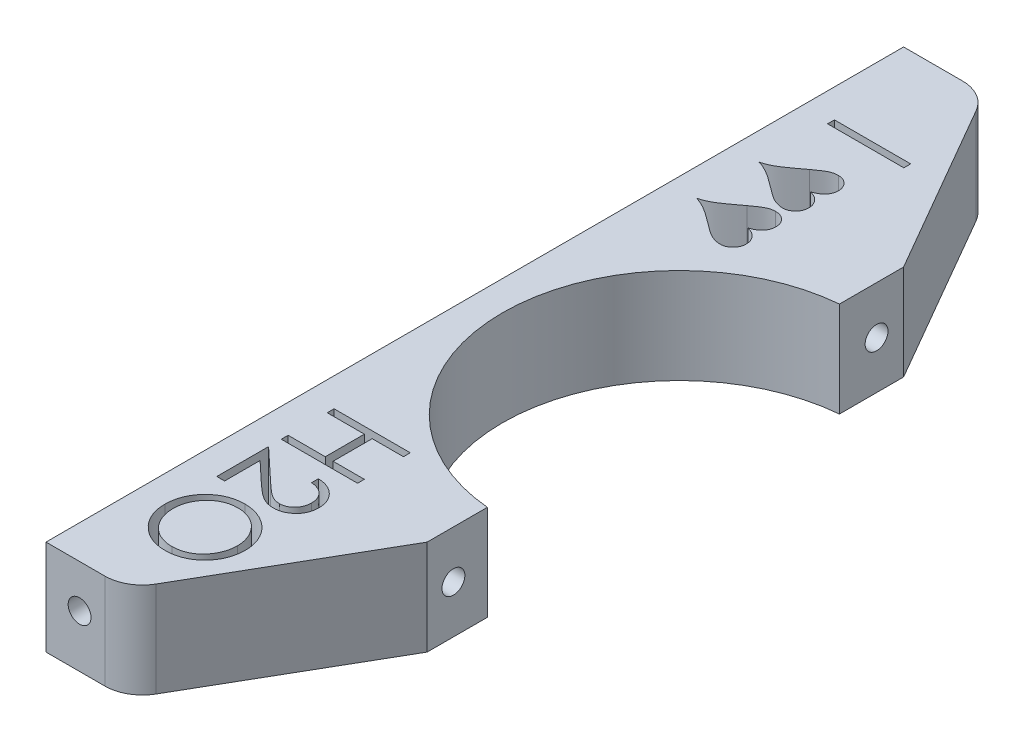
from build123d import *

# Parameters (mm, degrees)
SKETCH1_W               = 76.2
SKETCH1_H               = 25.4
BOSS_EXTRUDE1_DEPTH     = 228.6
CUT_EXTRUDE1_DEPTH      = 26.4
CUT_EXTRUDE2_DEPTH      = 1
CUT_EXTRUDE2_DEPTH_BACK = 26.4
FILLET1_R               = 10
SKETCH4_W               = 20.32
SKETCH4_H               = 1.823589744
CUT_EXTRUDE4_DEPTH      = 1
CUT_EXTRUDE4_DEPTH_BACK = 26.4
SKETCH5_R               = 3.048
CUT_EXTRUDE5_DEPTH      = 9.525
SKETCH6_R               = 3.048
CUT_EXTRUDE6_DEPTH      = 9.525
SKETCH7_R               = 3.048
CUT_EXTRUDE7_DEPTH      = 9.525


with BuildPart() as part:
    # Sketch1 → Boss-Extrude1 (new body)
    with BuildSketch(Plane.XY):
        with Locations((-76.99375, 46.83125)):
            Rectangle(SKETCH1_W, SKETCH1_H)
    extrude(amount=BOSS_EXTRUDE1_DEPTH)

    # Sketch2 → Cut-Extrude1 (cut, through all)
    with BuildSketch(Plane(origin=(0, 59.53125, 0), x_dir=(1, 0, 0), z_dir=(0, 1, 0))):
        with BuildLine():
            Line((-64.29375, -228.6), (-64.29375, -161.756428709))
            ThreePointArc((-64.29375, -161.756428709), (-107.195620062, -114.82835216), (-64.29375, -67.90027561))
            Line((-64.29375, -67.90027561), (-64.29375, 0))
            Line((-64.29375, 0), (-17.281394977, 0))
            Line((-17.281394977, 0), (-17.281394977, -228.6))
            Line((-17.281394977, -228.6), (-64.29375, -228.6))
        make_face()
    extrude(amount=-CUT_EXTRUDE1_DEPTH, mode=Mode.SUBTRACT)

    # Sketch3 → Cut-Extrude2 (cut, two sides)
    with BuildSketch(Plane(origin=(0, 59.53125, 0), x_dir=(1, 0, 0), z_dir=(0, 1, 0))) as cut_extrude2_sk:
        Polygon((-93.623143675, -228.6), (-64.29375, -177.8), (-64.29375, -228.6), align=None)
        Polygon((-64.29375, -50.8), (-64.29375, 0), (-93.623143675, 0), align=None)
    extrude(amount=CUT_EXTRUDE2_DEPTH, mode=Mode.SUBTRACT)
    extrude(cut_extrude2_sk.sketch, amount=-CUT_EXTRUDE2_DEPTH_BACK, mode=Mode.SUBTRACT)

    # Fillet1
    fillet1_edges = [part.edges().sort_by_distance(p)[0] for p in [
        (-93.623143675, 46.83125, 228.6),
        (-93.623143675, 46.83125, 0),
    ]]
    fillet(fillet1_edges, radius=FILLET1_R)

    # Sketch4 → Cut-Extrude4 (cut, two sides)
    with BuildSketch(Plane(origin=(0, 59.53125, 0), x_dir=(1, 0, 0), z_dir=(0, 1, 0))) as cut_extrude4_sk:
        with Locations((-97.31375, -26.963076923)):
            Rectangle(SKETCH4_W, SKETCH4_H)
        with BuildLine():
            add(Edge.make_bspline(
                [(-107.803461538, -45.854326923), (-107.526850389, -45.776645874), (-106.977385254, -45.622338906), (-106.178370987, -45.326274398), (-105.406394948, -44.9832244), (-104.770011222, -44.650701308), (-104.231404491, -44.329009584), (-103.753074851, -44.017533501), (-103.196094974, -43.643903935), (-102.565670745, -43.203380674), (-101.859529023, -42.696128207), (-101.076301016, -42.123935851), (-100.21751599, -41.484674215), (-99.622737732, -41.033947345), (-99.312371795, -40.79875)],
                knots=[0, 0, 0, 0, 0.000861652, 0.0017116, 0.002553488, 0.003394667, 0.003863783, 0.004435107, 0.00510684, 0.005875823, 0.00674223, 0.007715159, 0.008785712, 0.009953956, 0.009953956, 0.009953956, 0.009953956], degree=3))
            add(Edge.make_bspline(
                [(-99.312371795, -40.79875), (-99.165005098, -40.686776497), (-98.879106872, -40.46954271), (-98.455046356, -40.16561253), (-98.05592924, -39.885064707), (-97.683714936, -39.625677675), (-97.327760486, -39.403686206), (-96.998383735, -39.20360212), (-96.694197784, -39.027601265), (-96.320102113, -38.831590085), (-95.862629455, -38.632592026), (-95.302473383, -38.465056638), (-94.735792043, -38.358092228), (-94.353592554, -38.346123378), (-94.163173077, -38.340160256)],
                knots=[0, 0, 0, 0, 0.000555219, 0.00107715, 0.001565017, 0.002018893, 0.002437859, 0.002823206, 0.003175111, 0.003491906, 0.004089994, 0.004668194, 0.005243073, 0.005813875, 0.005813875, 0.005813875, 0.005813875], degree=3))
            add(Edge.make_bspline(
                [(-94.163173077, -38.340160256), (-94.039532597, -38.343169019), (-93.795337572, -38.349111449), (-93.438467093, -38.399565361), (-93.095126352, -38.477673481), (-92.765590485, -38.584457436), (-92.454695099, -38.735593374), (-92.157137289, -38.909977549), (-91.872167775, -39.114107608), (-91.612471479, -39.355142211), (-91.367949986, -39.611963694), (-91.155842297, -39.888618702), (-90.978381001, -40.182715606), (-90.832339204, -40.490884924), (-90.717760629, -40.81414718), (-90.635589469, -41.152234527), (-90.586236459, -41.505551865), (-90.580138886, -41.747022413), (-90.577051282, -41.869294872)],
                knots=[0, 0, 0, 0, 0.000370774, 0.000732295, 0.001078886, 0.001426433, 0.001768743, 0.00211361, 0.002460464, 0.002817789, 0.003174883, 0.003523334, 0.003861211, 0.004203521, 0.004544692, 0.004888259, 0.005245747, 0.005612454, 0.005612454, 0.005612454, 0.005612454], degree=3))
            add(Edge.make_bspline(
                [(-90.577051282, -41.869294872), (-90.579056913, -41.98473993), (-90.583010511, -42.212310801), (-90.624542712, -42.54759844), (-90.694929051, -42.869706417), (-90.786367328, -43.180276651), (-90.911204412, -43.474585155), (-91.057382126, -43.757737619), (-91.233564303, -44.027555167), (-91.438547428, -44.283193658), (-91.665878946, -44.529712244), (-91.925004608, -44.756344994), (-92.206906676, -44.973872335), (-92.517528017, -45.17728796), (-92.855603114, -45.367167084), (-93.218552431, -45.54793869), (-93.610998149, -45.710224252), (-93.884524314, -45.805482819), (-94.024775641, -45.854326923)],
                knots=[0, 0, 0, 0, 0.000346209, 0.000682464, 0.001011396, 0.001334611, 0.001652111, 0.001968905, 0.002289547, 0.002616939, 0.002951019, 0.003294127, 0.003648285, 0.00401859, 0.004406849, 0.00481098, 0.005234313, 0.005679806, 0.005679806, 0.005679806, 0.005679806], degree=3))
            add(Edge.make_bspline(
                [(-94.024775641, -45.854326923), (-93.881701598, -45.894489877), (-93.600961616, -45.973297652), (-93.200557373, -46.120656163), (-92.82539439, -46.28160126), (-92.484783147, -46.47115287), (-92.168531658, -46.672206164), (-91.886208473, -46.900131649), (-91.627672844, -47.141889845), (-91.335411327, -47.493773851), (-91.027166465, -47.952603298), (-90.758608176, -48.537588378), (-90.59050546, -49.146207833), (-90.570712948, -49.561512201), (-90.560769231, -49.770160256)],
                knots=[0, 0, 0, 0, 0.000445642, 0.000874439, 0.001279061, 0.001668897, 0.002042609, 0.002401784, 0.002755919, 0.00310251, 0.003771983, 0.004407674, 0.00502674, 0.005651772, 0.005651772, 0.005651772, 0.005651772], degree=3))
            add(Edge.make_bspline(
                [(-90.560769231, -49.770160256), (-90.563772929, -49.892440815), (-90.569671777, -50.132582901), (-90.61999156, -50.485774832), (-90.701901642, -50.823261745), (-90.811068738, -51.149328656), (-90.958610493, -51.458661419), (-91.13908087, -51.751983882), (-91.348500386, -52.032954331), (-91.590525137, -52.29279298), (-91.852510811, -52.530386842), (-92.126933023, -52.742027152), (-92.41605427, -52.916070217), (-92.716313319, -53.059234211), (-93.025679896, -53.176442916), (-93.349204083, -53.250143635), (-93.682474829, -53.303154795), (-93.909222366, -53.308687087), (-94.024775641, -53.31150641)],
                knots=[0, 0, 0, 0, 0.000366708, 0.000720163, 0.001067686, 0.001407519, 0.001749829, 0.0020933, 0.002439293, 0.002799367, 0.003156692, 0.003499438, 0.003837315, 0.004166851, 0.004496537, 0.004827277, 0.005160587, 0.005506964, 0.005506964, 0.005506964, 0.005506964], degree=3))
            add(Edge.make_bspline(
                [(-94.024775641, -53.31150641), (-94.220654224, -53.305714004), (-94.620620707, -53.293886431), (-95.227857333, -53.178005622), (-95.85477451, -53.008046529), (-96.391423166, -52.809179847), (-96.840036094, -52.598941793), (-97.216654097, -52.403726826), (-97.62024064, -52.161809139), (-98.059578877, -51.883565828), (-98.527688648, -51.562306126), (-99.029712667, -51.204350273), (-99.55962579, -50.802562277), (-99.921955972, -50.519599731), (-100.110192308, -50.372596154)],
                knots=[0, 0, 0, 0, 0.000587058, 0.001198719, 0.001848473, 0.002534991, 0.00291197, 0.003334363, 0.003806981, 0.004323038, 0.004894318, 0.005509935, 0.006172617, 0.006889131, 0.006889131, 0.006889131, 0.006889131], degree=3))
            add(Edge.make_bspline(
                [(-100.110192308, -50.372596154), (-100.313314069, -50.213328317), (-100.710768628, -49.901684071), (-101.302991426, -49.451440132), (-101.880381987, -49.03087008), (-102.436724331, -48.629388675), (-102.979241831, -48.261081202), (-103.500814577, -47.911617278), (-104.008880001, -47.592937543), (-104.496432979, -47.293108158), (-104.970081949, -47.025245762), (-105.423757012, -46.780312483), (-105.863265044, -46.563857205), (-106.282910465, -46.368602402), (-106.686881208, -46.199413555), (-107.07565551, -46.063235105), (-107.443195271, -45.941392767), (-107.686337002, -45.882632506), (-107.803461538, -45.854326923)],
                knots=[0, 0, 0, 0, 0.00077435, 0.001515195, 0.002231651, 0.0029173, 0.003573272, 0.004198715, 0.004800628, 0.005372372, 0.005915629, 0.006432825, 0.006918872, 0.007385119, 0.007821291, 0.00823201, 0.008620781, 0.008982118, 0.008982118, 0.008982118, 0.008982118], degree=3))
        make_face()
        with BuildLine():
            add(Edge.make_bspline(
                [(-107.803461538, -62.527147436), (-107.526850389, -62.449466387), (-106.977385254, -62.295159419), (-106.178370987, -61.999094911), (-105.406394948, -61.656044913), (-104.770011222, -61.32352182), (-104.231404491, -61.001830097), (-103.753074851, -60.690354014), (-103.196094974, -60.316724447), (-102.565670745, -59.876201187), (-101.859529023, -59.36894872), (-101.076301016, -58.796756364), (-100.21751599, -58.157494728), (-99.622737732, -57.706767858), (-99.312371795, -57.471570513)],
                knots=[0, 0, 0, 0, 0.000861652, 0.0017116, 0.002553488, 0.003394667, 0.003863783, 0.004435107, 0.00510684, 0.005875823, 0.00674223, 0.007715159, 0.008785712, 0.009953956, 0.009953956, 0.009953956, 0.009953956], degree=3))
            add(Edge.make_bspline(
                [(-99.312371795, -57.471570513), (-99.165005098, -57.35959701), (-98.879106872, -57.142363223), (-98.455046356, -56.838433043), (-98.05592924, -56.55788522), (-97.683714936, -56.298498188), (-97.327760486, -56.076506719), (-96.998383735, -55.876422633), (-96.694197784, -55.700421777), (-96.320102113, -55.504410598), (-95.862629455, -55.305412539), (-95.302473383, -55.137877151), (-94.735792043, -55.030912741), (-94.353592554, -55.018943891), (-94.163173077, -55.012980769)],
                knots=[0, 0, 0, 0, 0.000555219, 0.00107715, 0.001565017, 0.002018893, 0.002437859, 0.002823206, 0.003175111, 0.003491906, 0.004089994, 0.004668194, 0.005243073, 0.005813875, 0.005813875, 0.005813875, 0.005813875], degree=3))
            add(Edge.make_bspline(
                [(-94.163173077, -55.012980769), (-94.039532597, -55.015989532), (-93.795337572, -55.021931962), (-93.438467093, -55.072385874), (-93.095126352, -55.150493993), (-92.765590485, -55.257277949), (-92.454695099, -55.408413887), (-92.157137289, -55.582798062), (-91.872167775, -55.786928121), (-91.612471479, -56.027962724), (-91.367949986, -56.284784207), (-91.155842297, -56.561439215), (-90.978381001, -56.855536118), (-90.832339204, -57.163705437), (-90.717760629, -57.486967693), (-90.635589469, -57.825055039), (-90.586236459, -58.178372378), (-90.580138886, -58.419842926), (-90.577051282, -58.542115385)],
                knots=[0, 0, 0, 0, 0.000370774, 0.000732295, 0.001078886, 0.001426433, 0.001768743, 0.00211361, 0.002460464, 0.002817789, 0.003174883, 0.003523334, 0.003861211, 0.004203521, 0.004544692, 0.004888259, 0.005245747, 0.005612454, 0.005612454, 0.005612454, 0.005612454], degree=3))
            add(Edge.make_bspline(
                [(-90.577051282, -58.542115385), (-90.579056913, -58.657560443), (-90.583010511, -58.885131314), (-90.624542712, -59.220418952), (-90.694929051, -59.54252693), (-90.786367328, -59.853097164), (-90.911204412, -60.147405668), (-91.057382126, -60.430558132), (-91.233564303, -60.70037568), (-91.438547428, -60.956014171), (-91.665878946, -61.202532757), (-91.925004608, -61.429165507), (-92.206906676, -61.646692848), (-92.517528017, -61.850108473), (-92.855603114, -62.039987597), (-93.218552431, -62.220759202), (-93.610998149, -62.383044765), (-93.884524314, -62.478303332), (-94.024775641, -62.527147436)],
                knots=[0, 0, 0, 0, 0.000346209, 0.000682464, 0.001011396, 0.001334611, 0.001652111, 0.001968905, 0.002289547, 0.002616939, 0.002951019, 0.003294127, 0.003648285, 0.00401859, 0.004406849, 0.00481098, 0.005234313, 0.005679806, 0.005679806, 0.005679806, 0.005679806], degree=3))
            add(Edge.make_bspline(
                [(-94.024775641, -62.527147436), (-93.881701598, -62.56731039), (-93.600961616, -62.646118165), (-93.200557373, -62.793476676), (-92.82539439, -62.954421773), (-92.484783147, -63.143973383), (-92.168531658, -63.345026677), (-91.886208473, -63.572952162), (-91.627672844, -63.814710358), (-91.335411327, -64.166594364), (-91.027166465, -64.625423811), (-90.758608176, -65.210408891), (-90.59050546, -65.819028345), (-90.570712948, -66.234332714), (-90.560769231, -66.442980769)],
                knots=[0, 0, 0, 0, 0.000445642, 0.000874439, 0.001279061, 0.001668897, 0.002042609, 0.002401784, 0.002755919, 0.00310251, 0.003771983, 0.004407674, 0.00502674, 0.005651772, 0.005651772, 0.005651772, 0.005651772], degree=3))
            add(Edge.make_bspline(
                [(-90.560769231, -66.442980769), (-90.563772929, -66.565261328), (-90.569671777, -66.805403414), (-90.61999156, -67.158595345), (-90.701901642, -67.496082257), (-90.811068738, -67.822149169), (-90.958610493, -68.131481932), (-91.13908087, -68.424804395), (-91.348500386, -68.705774844), (-91.590525137, -68.965613493), (-91.852510811, -69.203207355), (-92.126933023, -69.414847664), (-92.41605427, -69.58889073), (-92.716313319, -69.732054724), (-93.025679896, -69.849263429), (-93.349204083, -69.922964148), (-93.682474829, -69.975975308), (-93.909222366, -69.9815076), (-94.024775641, -69.984326923)],
                knots=[0, 0, 0, 0, 0.000366708, 0.000720163, 0.001067686, 0.001407519, 0.001749829, 0.0020933, 0.002439293, 0.002799367, 0.003156692, 0.003499438, 0.003837315, 0.004166851, 0.004496537, 0.004827277, 0.005160587, 0.005506964, 0.005506964, 0.005506964, 0.005506964], degree=3))
            add(Edge.make_bspline(
                [(-94.024775641, -69.984326923), (-94.220654224, -69.978534517), (-94.620620707, -69.966706944), (-95.227857333, -69.850826135), (-95.85477451, -69.680867042), (-96.391423166, -69.48200036), (-96.840036094, -69.271762306), (-97.216654097, -69.076547339), (-97.62024064, -68.834629652), (-98.059578877, -68.556386341), (-98.527688648, -68.235126638), (-99.029712667, -67.877170785), (-99.55962579, -67.475382789), (-99.921955972, -67.192420243), (-100.110192308, -67.045416667)],
                knots=[0, 0, 0, 0, 0.000587058, 0.001198719, 0.001848473, 0.002534991, 0.00291197, 0.003334363, 0.003806981, 0.004323038, 0.004894318, 0.005509935, 0.006172617, 0.006889131, 0.006889131, 0.006889131, 0.006889131], degree=3))
            add(Edge.make_bspline(
                [(-100.110192308, -67.045416667), (-100.313314069, -66.88614883), (-100.710768628, -66.574504584), (-101.302991426, -66.124260645), (-101.880381987, -65.703690593), (-102.436724331, -65.302209188), (-102.979241831, -64.933901715), (-103.500814577, -64.584437791), (-104.008880001, -64.265758056), (-104.496432979, -63.96592867), (-104.970081949, -63.698066275), (-105.423757012, -63.453132995), (-105.863265044, -63.236677718), (-106.282910465, -63.041422915), (-106.686881208, -62.872234068), (-107.07565551, -62.736055617), (-107.443195271, -62.61421328), (-107.686337002, -62.555453019), (-107.803461538, -62.527147436)],
                knots=[0, 0, 0, 0, 0.00077435, 0.001515195, 0.002231651, 0.0029173, 0.003573272, 0.004198715, 0.004800628, 0.005372372, 0.005915629, 0.006432825, 0.006918872, 0.007385119, 0.007821291, 0.00823201, 0.008620781, 0.008982118, 0.008982118, 0.008982118, 0.008982118], degree=3))
        make_face()
        Polygon((-87.15375, -159.433846154), (-87.15375, -161.257435897), (-95.490160256, -161.257435897), (-95.490160256, -171.677948718), (-87.15375, -171.677948718), (-87.15375, -173.501538462), (-107.47375, -173.501538462), (-107.47375, -171.677948718), (-97.574262821, -171.677948718), (-97.574262821, -161.257435897), (-107.47375, -161.257435897), (-107.47375, -159.433846154), align=None)
        with BuildLine():
            Line((-93.406057692, -179.493333333), (-93.406057692, -177.66974359))
            add(Edge.make_bspline(
                [(-93.406057692, -177.66974359), (-93.164127231, -177.681626752), (-92.688982245, -177.704964967), (-91.996238611, -177.814305261), (-91.334007964, -177.970612694), (-90.707967713, -178.192136793), (-90.110639284, -178.465699696), (-89.549954506, -178.800619857), (-89.020348649, -179.189757318), (-88.531848909, -179.632398192), (-88.08529907, -180.112704336), (-87.695599703, -180.62779797), (-87.370109, -181.172384903), (-87.096526558, -181.741741623), (-86.891419059, -182.342452908), (-86.739165815, -182.96877663), (-86.647577741, -183.623543708), (-86.63773182, -184.06965442), (-86.632724359, -184.296538462)],
                knots=[0, 0, 0, 0, 0.000726196, 0.001426229, 0.002100535, 0.002764815, 0.003415002, 0.004068418, 0.004720539, 0.005383445, 0.006043082, 0.006685411, 0.00731718, 0.007943524, 0.008576878, 0.009217618, 0.009875028, 0.010555401, 0.010555401, 0.010555401, 0.010555401], degree=3))
            add(Edge.make_bspline(
                [(-86.632724359, -184.296538462), (-86.63794054, -184.519350595), (-86.648190151, -184.957168477), (-86.736210755, -185.596157086), (-86.874070875, -186.204464122), (-87.067490664, -186.780900526), (-87.327496254, -187.320867164), (-87.639829392, -187.828420382), (-88.001059956, -188.30960269), (-88.426350667, -188.742748359), (-88.880371368, -189.140486693), (-89.365078283, -189.4836175), (-89.865700879, -189.777463067), (-90.386056609, -190.022392682), (-90.93104498, -190.202695752), (-91.492731597, -190.339584091), (-92.0769305, -190.416959247), (-92.472337703, -190.428834392), (-92.673365385, -190.434871795)],
                knots=[0, 0, 0, 0, 0.000668172, 0.001312934, 0.001931062, 0.00253735, 0.003132718, 0.003724722, 0.004323101, 0.004933407, 0.005542258, 0.00613185, 0.006711995, 0.007282012, 0.007853539, 0.008431107, 0.009014271, 0.00961738, 0.00961738, 0.00961738, 0.00961738], degree=3))
            add(Edge.make_bspline(
                [(-92.673365385, -190.434871795), (-92.956381384, -190.425041195), (-93.517446853, -190.405552507), (-94.341944571, -190.238845041), (-95.14077265, -189.978479011), (-95.783681786, -189.664985784), (-96.301745956, -189.348734338), (-96.728284265, -189.063746294), (-97.187548013, -188.730122019), (-97.677999298, -188.343005711), (-98.203479752, -187.910405265), (-98.763671936, -187.428402305), (-99.35278804, -186.89355969), (-99.75515656, -186.518170908), (-99.963653846, -186.323653846)],
                knots=[0, 0, 0, 0, 0.000848319, 0.001681751, 0.002513292, 0.003363483, 0.003820035, 0.00433371, 0.004902024, 0.005522507, 0.006207866, 0.006943864, 0.007739292, 0.00859473, 0.00859473, 0.00859473, 0.00859473], degree=3))
            Line((-99.963653846, -186.323653846), (-105.389647436, -181.239583333))
            Line((-105.389647436, -181.239583333), (-105.389647436, -190.695384615))
            Line((-105.389647436, -190.695384615), (-107.47375, -190.695384615))
            Line((-107.47375, -190.695384615), (-107.47375, -176.888205128))
            Line((-107.47375, -176.888205128), (-99.064070513, -184.768717949))
            add(Edge.make_bspline(
                [(-99.064070513, -184.768717949), (-98.863794126, -184.960598121), (-98.479104174, -185.329160663), (-97.917298466, -185.850233935), (-97.396715533, -186.318994328), (-96.915048548, -186.735752794), (-96.475028113, -187.100852243), (-96.073205891, -187.413124517), (-95.713030204, -187.673949804), (-95.289910866, -187.950370256), (-94.772694119, -188.2139555), (-94.143807568, -188.445619958), (-93.494986524, -188.585866469), (-93.056665254, -188.602776274), (-92.836185897, -188.611282051)],
                knots=[0, 0, 0, 0, 0.000832069, 0.001598234, 0.002298658, 0.002933554, 0.003508938, 0.004013747, 0.004459965, 0.004842723, 0.005529048, 0.006196066, 0.006849101, 0.007510043, 0.007510043, 0.007510043, 0.007510043], degree=3))
            add(Edge.make_bspline(
                [(-92.836185897, -188.611282051), (-92.697522, -188.607629026), (-92.424242086, -188.600429616), (-92.023834198, -188.535687797), (-91.636096489, -188.440569215), (-91.265823057, -188.293962098), (-90.905731339, -188.117819044), (-90.566769247, -187.892783303), (-90.237382377, -187.635626546), (-89.928865131, -187.337337322), (-89.646215427, -187.009871178), (-89.395854671, -186.663872755), (-89.186620491, -186.297824797), (-89.015099762, -185.913252787), (-88.880550019, -185.51123359), (-88.787318522, -185.090988383), (-88.728782494, -184.653678682), (-88.720862502, -184.355070499), (-88.716826923, -184.202916667)],
                knots=[0, 0, 0, 0, 0.000415691, 0.000819247, 0.00121415, 0.001611019, 0.002011505, 0.002414568, 0.002829061, 0.003263768, 0.003699541, 0.004125411, 0.004542951, 0.004962036, 0.005386815, 0.005812432, 0.006251689, 0.006708041, 0.006708041, 0.006708041, 0.006708041], degree=3))
            add(Edge.make_bspline(
                [(-88.716826923, -184.202916667), (-88.720976941, -184.044008727), (-88.72912689, -183.73193977), (-88.786172283, -183.27376842), (-88.884490156, -182.836644284), (-89.019281877, -182.419682496), (-89.188985722, -182.02248132), (-89.404437531, -181.648632247), (-89.65722527, -181.294722159), (-89.945389494, -180.961401062), (-90.26773533, -180.655131272), (-90.622643098, -180.380382384), (-91.012421428, -180.146050626), (-91.428266406, -179.938326069), (-91.881234828, -179.77938604), (-92.360350232, -179.643525633), (-92.872419698, -179.544833093), (-93.225223966, -179.510785039), (-93.406057692, -179.493333333)],
                knots=[0, 0, 0, 0, 0.000476685, 0.00093613, 0.001382497, 0.001818878, 0.002249141, 0.002675768, 0.003110628, 0.003552143, 0.003995548, 0.004442527, 0.004895599, 0.005357992, 0.005834433, 0.006333183, 0.006851291, 0.007396101, 0.007396101, 0.007396101, 0.007396101], degree=3))
        make_face()
        with BuildLine():
            add(Edge.make_bspline(
                [(-86.632724359, -203.851282051), (-86.642254406, -204.227539322), (-86.660972205, -204.966539644), (-86.804250795, -206.052644126), (-87.052132551, -207.089512281), (-87.382246288, -208.085613863), (-87.822696095, -209.02894856), (-88.354765519, -209.926936829), (-88.986021842, -210.777039716), (-89.705872874, -211.571465001), (-90.491955167, -212.295770703), (-91.333265005, -212.928591606), (-92.218281962, -213.463636898), (-93.150085665, -213.902176008), (-94.124574914, -214.246525187), (-95.147290476, -214.484068087), (-96.211512441, -214.635824559), (-96.937383288, -214.653564726), (-97.305608974, -214.662564103)],
                knots=[0, 0, 0, 0, 0.00112859, 0.002216643, 0.003279008, 0.004322942, 0.005359205, 0.006395876, 0.007449345, 0.008530087, 0.009607551, 0.010651231, 0.011683008, 0.01270452, 0.01373571, 0.014777332, 0.015849794, 0.016953984, 0.016953984, 0.016953984, 0.016953984], degree=3))
            add(Edge.make_bspline(
                [(-97.305608974, -214.662564103), (-97.671122235, -214.65356606), (-98.391591218, -214.635829876), (-99.449059494, -214.483895366), (-100.465602644, -214.245645311), (-101.439424977, -213.90537028), (-102.371919938, -213.468937914), (-103.258563648, -212.930276496), (-104.1056988, -212.301645277), (-104.895597164, -211.579843073), (-105.621325755, -210.79394824), (-106.255130525, -209.95026597), (-106.796763497, -209.06612), (-107.232294704, -208.13487959), (-107.579080931, -207.166926528), (-107.815742227, -206.15338956), (-107.968340077, -205.098791179), (-107.985867092, -204.379632955), (-107.994775641, -204.014102564)],
                knots=[0, 0, 0, 0, 0.001096057, 0.002160455, 0.003198117, 0.00422412, 0.005249316, 0.006281092, 0.007331293, 0.008409018, 0.009486482, 0.010535861, 0.011569748, 0.01259126, 0.013614773, 0.014648475, 0.015708842, 0.016804899, 0.016804899, 0.016804899, 0.016804899], degree=3))
            add(Edge.make_bspline(
                [(-107.994775641, -204.014102564), (-107.985781551, -203.645878369), (-107.968051805, -202.920010462), (-107.816032739, -201.854457198), (-107.578402702, -200.831001123), (-107.238481429, -199.852793443), (-106.800826928, -198.919513152), (-106.263014539, -198.031250511), (-105.629276503, -197.186938133), (-104.908435287, -196.395167875), (-104.122162761, -195.671596892), (-103.284026053, -195.035174431), (-102.401996324, -194.500462645), (-101.479709468, -194.06262339), (-100.519549436, -193.71630921), (-99.515476463, -193.479966779), (-98.47311692, -193.327073703), (-97.763410193, -193.309453436), (-97.403301282, -193.300512821)],
                knots=[0, 0, 0, 0, 0.00110419, 0.002176652, 0.003222235, 0.004252083, 0.005277279, 0.006309055, 0.00736169, 0.008439416, 0.00951688, 0.01056301, 0.011591304, 0.012605458, 0.013621302, 0.014647087, 0.015695361, 0.016775152, 0.016775152, 0.016775152, 0.016775152], degree=3))
            add(Edge.make_bspline(
                [(-97.403301282, -193.300512821), (-97.161592795, -193.303613915), (-96.681225083, -193.309776983), (-95.967912961, -193.384083773), (-95.265995424, -193.491690754), (-94.57783198, -193.646715112), (-93.903310252, -193.846683383), (-93.243809675, -194.093110354), (-92.593897903, -194.375515757), (-91.965943908, -194.711758399), (-91.358962074, -195.078609184), (-90.780542201, -195.478623107), (-90.241016433, -195.914589249), (-89.731715453, -196.380279939), (-89.261331873, -196.882141378), (-88.819610246, -197.412620567), (-88.411123112, -197.974493214), (-88.044449825, -198.568647934), (-87.707655957, -199.179936529), (-87.426460793, -199.812793925), (-87.177921978, -200.453867469), (-86.980407322, -201.108803988), (-86.823223981, -201.776088505), (-86.716421874, -202.456555198), (-86.641949976, -203.149503197), (-86.635812796, -203.616349301), (-86.632724359, -203.851282051)],
                knots=[0, 0, 0, 0, 0.000724837, 0.00144053, 0.002149232, 0.002854324, 0.003554949, 0.004258147, 0.004965304, 0.005679085, 0.006393236, 0.007092192, 0.007787023, 0.00847266, 0.009160865, 0.009848818, 0.010542527, 0.011242809, 0.011942239, 0.012634525, 0.013318674, 0.014003707, 0.014684992, 0.015373595, 0.016069033, 0.016773526, 0.016773526, 0.016773526, 0.016773526], degree=3))
        make_face()
        with BuildLine():
            add(Edge.make_bspline(
                [(-88.716826923, -203.940833333), (-88.719176481, -203.747998221), (-88.723853135, -203.364171512), (-88.785501492, -202.793566084), (-88.873279007, -202.230434125), (-88.998807582, -201.674806276), (-89.168266604, -201.129672586), (-89.367937912, -200.589589156), (-89.602820948, -200.057149276), (-89.876700416, -199.538305244), (-90.175883992, -199.033924309), (-90.504248335, -198.554720456), (-90.860201226, -198.105474067), (-91.239040764, -197.684746045), (-91.644621495, -197.293762383), (-92.07047032, -196.924597577), (-92.52884634, -196.592109498), (-93.007296564, -196.287392493), (-93.505204083, -196.01471083), (-94.017325265, -195.77223306), (-94.547838027, -195.573886601), (-95.09098673, -195.412125601), (-95.645911183, -195.2780147), (-96.216821025, -195.193054318), (-96.800847504, -195.130745305), (-97.195530726, -195.126333859), (-97.395160256, -195.124102564)],
                knots=[0, 0, 0, 0, 0.000578242, 0.001150956, 0.00171978, 0.002287569, 0.002857979, 0.003431112, 0.004014276, 0.004602363, 0.005190154, 0.00577275, 0.006343624, 0.006908502, 0.007469834, 0.008032758, 0.008597783, 0.009166913, 0.009733475, 0.010299803, 0.010865312, 0.011430644, 0.011999352, 0.012576217, 0.013161083, 0.01375967, 0.01375967, 0.01375967, 0.01375967], degree=3))
            add(Edge.make_bspline(
                [(-97.395160256, -195.124102564), (-97.688710064, -195.131504048), (-98.266213348, -195.146065058), (-99.112501544, -195.273544436), (-99.925814109, -195.469905156), (-100.701700851, -195.759362781), (-101.446831087, -196.121352635), (-102.154594712, -196.568548752), (-102.825183011, -197.098372929), (-103.453914401, -197.700213747), (-104.027784899, -198.358133003), (-104.53150846, -199.056750452), (-104.957707396, -199.788581682), (-105.304918559, -200.555535133), (-105.580049837, -201.353516274), (-105.76861149, -202.187667085), (-105.892711277, -203.052430896), (-105.904628991, -203.641888871), (-105.910673077, -203.940833333)],
                knots=[0, 0, 0, 0, 0.000880173, 0.001731572, 0.002561846, 0.003386063, 0.004210731, 0.005043049, 0.005892382, 0.006770491, 0.007650447, 0.008507868, 0.009350542, 0.010186674, 0.01102982, 0.011877992, 0.012748978, 0.013645239, 0.013645239, 0.013645239, 0.013645239], degree=3))
            add(Edge.make_bspline(
                [(-105.910673077, -203.940833333), (-105.907912443, -204.141766217), (-105.902437276, -204.540276474), (-105.847290552, -205.133013822), (-105.758859118, -205.715073059), (-105.631534344, -206.285635896), (-105.472189822, -206.844061736), (-105.282855894, -207.392655528), (-105.046758216, -207.925670562), (-104.785479722, -208.449465597), (-104.489762977, -208.950932862), (-104.16598851, -209.426703445), (-103.816401446, -209.874019109), (-103.440851695, -210.293848713), (-103.042576599, -210.687541455), (-102.611335848, -211.044406925), (-102.159723654, -211.380878157), (-101.680157443, -211.684375042), (-101.181200691, -211.956514567), (-100.66713966, -212.193156758), (-100.139741, -212.394041087), (-99.598110841, -212.55617815), (-99.043313463, -212.68324101), (-98.474596413, -212.77079014), (-97.893100005, -212.832031517), (-97.499798517, -212.836647486), (-97.301538462, -212.838974359)],
                knots=[0, 0, 0, 0, 0.000602656, 0.001195248, 0.001784179, 0.002367854, 0.00294767, 0.003525698, 0.004107226, 0.004695214, 0.005280929, 0.00585221, 0.006420567, 0.006982726, 0.007541143, 0.008098803, 0.008660549, 0.009229679, 0.009799812, 0.010364426, 0.010926128, 0.01149146, 0.012059249, 0.012632093, 0.01321696, 0.013811478, 0.013811478, 0.013811478, 0.013811478], degree=3))
            add(Edge.make_bspline(
                [(-97.301538462, -212.838974359), (-97.104634734, -212.836645612), (-96.714039919, -212.832026112), (-96.136598825, -212.770819517), (-95.571974466, -212.683148062), (-95.022383473, -212.556799997), (-94.48768575, -212.393948819), (-93.968383489, -212.19314466), (-93.462542082, -211.956356865), (-92.971411764, -211.684601688), (-92.500134427, -211.37912925), (-92.049596996, -211.045334099), (-91.62826038, -210.677452996), (-91.225723012, -210.285996745), (-90.850569796, -209.861187551), (-90.502677565, -209.404949362), (-90.173645666, -208.922822372), (-89.876836985, -208.41233861), (-89.602680747, -207.885517703), (-89.367995432, -207.344878403), (-89.167403056, -206.795598183), (-88.99950121, -206.240489331), (-88.873156024, -205.675641328), (-88.785532985, -205.104343525), (-88.723846535, -204.525619425), (-88.719174219, -204.136380605), (-88.716826923, -203.940833333)],
                knots=[0, 0, 0, 0, 0.000590449, 0.001171264, 0.001740088, 0.002303909, 0.002861451, 0.003415549, 0.003972778, 0.004535776, 0.005098052, 0.005656529, 0.006216369, 0.006774786, 0.007339987, 0.00791478, 0.008495082, 0.009089878, 0.00968519, 0.010275807, 0.01085658, 0.011438677, 0.012014406, 0.012591272, 0.013172087, 0.013758467, 0.013758467, 0.013758467, 0.013758467], degree=3))
        make_face(mode=Mode.SUBTRACT)
    extrude(amount=CUT_EXTRUDE4_DEPTH, mode=Mode.SUBTRACT)
    extrude(cut_extrude4_sk.sketch, amount=-CUT_EXTRUDE4_DEPTH_BACK, mode=Mode.SUBTRACT)

    # Sketch5 → Cut-Extrude5 (cut)
    with BuildSketch(Plane.XY.offset(228.6)):
        with Locations((-106.14025, 48.10125)):
            Circle(SKETCH5_R)
    extrude(amount=-CUT_EXTRUDE5_DEPTH, mode=Mode.SUBTRACT)

    # Sketch6 → Cut-Extrude6 (cut)
    with BuildSketch(Plane(origin=(0, 0, 0), x_dir=(-1, 0, 0), z_dir=(0, 0, -1))):
        with Locations((106.14025, 48.10125)):
            Circle(SKETCH6_R)
    extrude(amount=-CUT_EXTRUDE6_DEPTH, mode=Mode.SUBTRACT)

    # Sketch7 → Cut-Extrude7 (cut)
    with BuildSketch(Plane(origin=(-64.29375, 0, 0), x_dir=(0, 0, -1), z_dir=(1, 0, 0))):
        with Locations((-170.799521079, 46.83125)):
            Circle(SKETCH7_R)
        with Locations((-58.005216258, 46.83125)):
            Circle(SKETCH7_R)
    extrude(amount=-CUT_EXTRUDE7_DEPTH, mode=Mode.SUBTRACT)


solid = part.part
